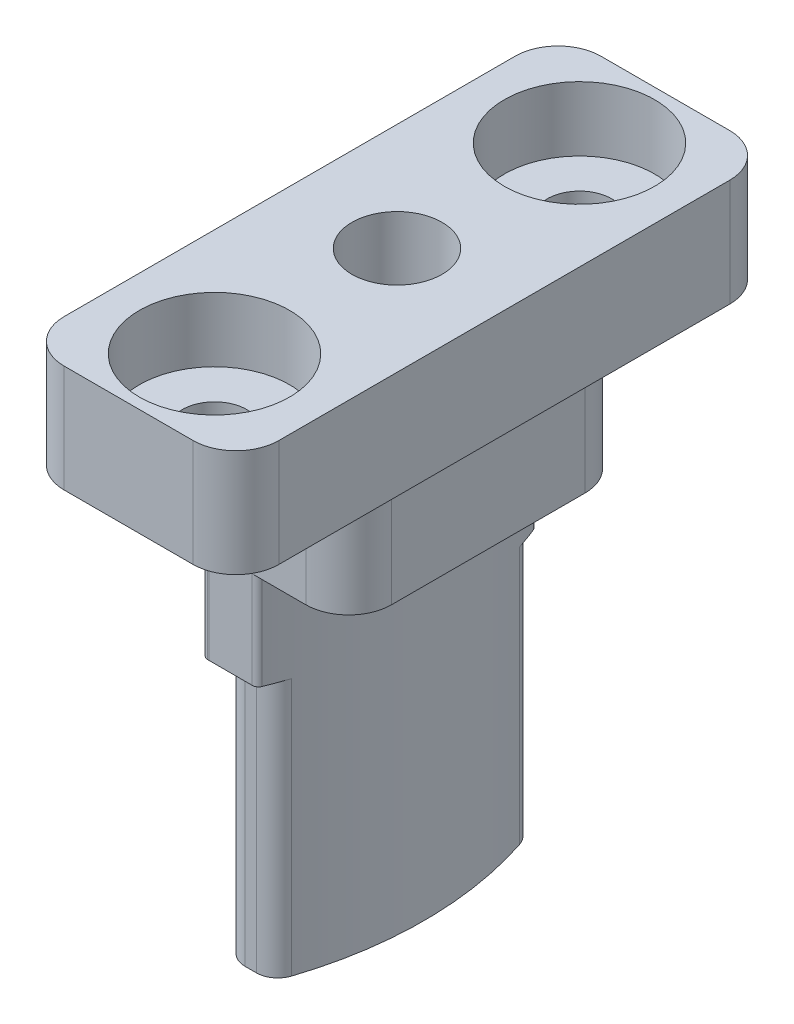
from build123d import *

# Parameters (mm, degrees)
SKETCH1_W           = 123.5
SKETCH1_H           = 81.5
BOSS_EXTRUDE1_DEPTH = 8
CHAMFER1_SIZE       = 10
SKETCH2_W           = 130
SKETCH2_H           = 88
BOSS_EXTRUDE2_DEPTH = 9
FILLET1_R           = 2
SKETCH3_W           = 124
SKETCH3_H           = 82
CUT_EXTRUDE1_DEPTH  = 2
FILLET2_R           = 2
SKETCH4_R           = 10
CUT_EXTRUDE2_DEPTH  = 18
SKETCH5_R           = 17
SKETCH5_R_2         = 14.5
BOSS_EXTRUDE3_DEPTH = 16.5
SKETCH6_W           = 170
SKETCH6_H           = 36.5
SKETCH6_W_2         = 114
SKETCH6_H_2         = 12
CUT_EXTRUDE3_DEPTH  = 12
FILLET3_R           = 1
SKETCH7_R           = 0.85
CUT_EXTRUDE4_DEPTH  = 20.75
SKETCH11_W          = 130
SKETCH11_H          = 10
CUT_EXTRUDE8_DEPTH  = 85.75
SKETCH13_R          = 2.1
CUT_EXTRUDE9_DEPTH  = 6
SKETCH15_R          = 2.1
SKETCH15_R_2        = 10
BOSS_EXTRUDE4_DEPTH = 3
SKETCH16_W          = 188.077165187
SKETCH16_H          = 117.101438596
SKETCH16_W_2        = 10
SKETCH16_H_2        = 25
CUT_EXTRUDE10_DEPTH = 27.5
CUT_EXTRUDE11_START = -5
SKETCH17_W          = 10
SKETCH17_H          = 25
SKETCH17_W_2        = 8.5
SKETCH17_H_2        = 13
CUT_EXTRUDE11_DEPTH = 22.5
FILLET4_R           = 2
SKETCH18_R          = 1.5
CUT_EXTRUDE12_DEPTH = 27.5
SKETCH19_R          = 3.5
CUT_EXTRUDE13_DEPTH = 3
FILLET5_R           = 0.3


with BuildPart() as part:
    # Sketch1 → Boss-Extrude1 (new body)
    with BuildSketch(Plane(origin=(0, 0, 0), x_dir=(1, 0, 0), z_dir=(0, 1, 0))):
        with Locations((61.75, -40.75)):
            Rectangle(SKETCH1_W, SKETCH1_H)
    extrude(amount=BOSS_EXTRUDE1_DEPTH)

    # Chamfer1
    chamfer1_edges = [part.edges().sort_by_distance(p)[0] for p in [
        (123.5, 4, 0),
        (123.5, 4, 81.5),
    ]]
    chamfer(chamfer1_edges, length=CHAMFER1_SIZE)

    # Sketch2 → Boss-Extrude2 (add)
    with BuildSketch(Plane.XZ):
        with Locations((61.75, 40.75)):
            Rectangle(SKETCH2_W, SKETCH2_H)
    extrude(amount=BOSS_EXTRUDE2_DEPTH)

    # Fillet1
    fillet1_edges = [part.edges().sort_by_distance(p)[0] for p in [
        (113.5, 4, 0),
        (123.5, 4, 71.5),
        (123.5, 4, 10),
        (113.5, 4, 81.5),
        (-3.25, -4.5, 84.75),
        (-3.25, -4.5, -3.25),
        (126.75, -4.5, -3.25),
        (126.75, -4.5, 84.75),
        (0, 4, 0),
        (0, 4, 81.5),
    ]]
    fillet(fillet1_edges, radius=FILLET1_R)

    # Sketch3 → Cut-Extrude1 (cut)
    with BuildSketch(Plane.XZ.offset(9)):
        with Locations((61.75, 40.75)):
            Rectangle(SKETCH3_W, SKETCH3_H)
    extrude(amount=-CUT_EXTRUDE1_DEPTH, mode=Mode.SUBTRACT)

    # Fillet2
    fillet2_edges = [part.edges().sort_by_distance(p)[0] for p in [
        (-0.25, -8, -0.25),
        (-0.25, -8, 81.75),
        (123.75, -8, 81.75),
        (123.75, -8, -0.25),
    ]]
    fillet(fillet2_edges, radius=FILLET2_R)

    # Sketch4 → Cut-Extrude2 (cut, through all)
    with BuildSketch(Plane(origin=(0, 8, 0), x_dir=(1, 0, 0), z_dir=(0, 1, 0))):
        with Locations((22.5, -20.85)):
            Circle(SKETCH4_R)
        with Locations((61.5, -20.85)):
            Circle(SKETCH4_R)
        with Locations((100.5, -20.85)):
            Circle(SKETCH4_R)
        with Locations((100.5, -60.65)):
            Circle(SKETCH4_R)
        with Locations((61.5, -60.65)):
            Circle(SKETCH4_R)
        with Locations((22.5, -60.65)):
            Circle(SKETCH4_R)
    extrude(amount=-CUT_EXTRUDE2_DEPTH, mode=Mode.SUBTRACT)

    # Sketch5 → Boss-Extrude3 (add)
    with BuildSketch(Plane.XZ.offset(7)):
        with Locations((22.5, 60.65)):
            Circle(SKETCH5_R)
        with Locations((22.5, 60.65)):
            Circle(SKETCH5_R_2, mode=Mode.SUBTRACT)
        with Locations((61.5, 60.65)):
            Circle(SKETCH5_R)
        with Locations((61.5, 60.65)):
            Circle(SKETCH5_R_2, mode=Mode.SUBTRACT)
        with Locations((100.5, 60.65)):
            Circle(SKETCH5_R)
        with Locations((100.5, 60.65)):
            Circle(SKETCH5_R_2, mode=Mode.SUBTRACT)
        with Locations((100.5, 20.85)):
            Circle(SKETCH5_R)
        with Locations((100.5, 20.85)):
            Circle(SKETCH5_R_2, mode=Mode.SUBTRACT)
        with Locations((61.5, 20.85)):
            Circle(SKETCH5_R)
        with Locations((61.5, 20.85)):
            Circle(SKETCH5_R_2, mode=Mode.SUBTRACT)
        with Locations((22.5, 20.85)):
            Circle(SKETCH5_R)
        with Locations((22.5, 20.85)):
            Circle(SKETCH5_R_2, mode=Mode.SUBTRACT)
    extrude(amount=BOSS_EXTRUDE3_DEPTH)

    # Sketch6 → Cut-Extrude3 (cut)
    with BuildSketch(Plane.XZ.offset(23.5)):
        with Locations((61.5, 20.85)):
            Rectangle(SKETCH6_W, SKETCH6_H)
        with Locations((61.5, 20.85)):
            Rectangle(SKETCH6_W_2, SKETCH6_H_2, mode=Mode.SUBTRACT)
        with Locations((61.5, 60.65)):
            Rectangle(SKETCH6_W, SKETCH6_H)
        with Locations((61.5, 60.65)):
            Rectangle(SKETCH6_W_2, SKETCH6_H_2, mode=Mode.SUBTRACT)
    extrude(amount=-CUT_EXTRUDE3_DEPTH, mode=Mode.SUBTRACT)

    # Fillet3
    fillet3_edges = [part.edges().sort_by_distance(p)[0] for p in [
        (87.299621218, -17.5, 66.65),
        (113.700378782, -17.5, 66.65),
        (113.700378782, -17.5, 54.65),
        (87.299621218, -17.5, 54.65),
        (9.299621218, -17.5, 54.65),
        (35.700378782, -17.5, 54.65),
        (6.594026279, -17.5, 54.65),
        (48.299621218, -17.5, 54.65),
        (74.700378782, -17.5, 54.65),
        (38.405973721, -17.5, 54.65),
        (45.594026279, -17.5, 54.65),
        (77.405973721, -17.5, 54.65),
        (84.594026279, -17.5, 54.65),
        (35.700378782, -17.5, 66.65),
        (9.299621218, -17.5, 66.65),
        (38.405973721, -17.5, 66.65),
        (45.594026279, -17.5, 66.65),
        (74.700378782, -17.5, 66.65),
        (48.299621218, -17.5, 66.65),
        (77.405973721, -17.5, 66.65),
        (84.594026279, -17.5, 66.65),
        (116.405973721, -17.5, 66.65),
        (116.405973721, -17.5, 54.65),
        (6.594026279, -17.5, 66.65),
        (35.700378782, -17.5, 14.85),
        (9.299621218, -17.5, 14.85),
        (9.299621218, -17.5, 26.85),
        (35.700378782, -17.5, 26.85),
        (113.700378782, -17.5, 26.85),
        (87.299621218, -17.5, 26.85),
        (116.405973721, -17.5, 26.85),
        (74.700378782, -17.5, 26.85),
        (48.299621218, -17.5, 26.85),
        (84.594026279, -17.5, 26.85),
        (77.405973721, -17.5, 26.85),
        (45.594026279, -17.5, 26.85),
        (38.405973721, -17.5, 26.85),
        (87.299621218, -17.5, 14.85),
        (113.700378782, -17.5, 14.85),
        (84.594026279, -17.5, 14.85),
        (77.405973721, -17.5, 14.85),
        (48.299621218, -17.5, 14.85),
        (74.700378782, -17.5, 14.85),
        (45.594026279, -17.5, 14.85),
        (38.405973721, -17.5, 14.85),
        (6.594026279, -17.5, 14.85),
        (6.594026279, -17.5, 26.85),
        (116.405973721, -17.5, 14.85),
    ]]
    fillet(fillet3_edges, radius=FILLET3_R)

    # Sketch7 → Cut-Extrude4 (cut)
    with BuildSketch(Plane.XZ.offset(23.5)):
        with Locations((6.75, 20.85)):
            Circle(SKETCH7_R)
        with Locations((38.25, 20.85)):
            Circle(SKETCH7_R)
        with Locations((45.75, 20.85)):
            Circle(SKETCH7_R)
        with Locations((77.25, 20.85)):
            Circle(SKETCH7_R)
        with Locations((84.75, 20.85)):
            Circle(SKETCH7_R)
        with Locations((116.25, 20.85)):
            Circle(SKETCH7_R)
        with Locations((116.25, 60.65)):
            Circle(SKETCH7_R)
        with Locations((84.75, 60.65)):
            Circle(SKETCH7_R)
        with Locations((77.25, 60.65)):
            Circle(SKETCH7_R)
        with Locations((45.75, 60.65)):
            Circle(SKETCH7_R)
        with Locations((38.25, 60.65)):
            Circle(SKETCH7_R)
        with Locations((6.75, 60.65)):
            Circle(SKETCH7_R)
    extrude(amount=-CUT_EXTRUDE4_DEPTH, mode=Mode.SUBTRACT)

    # Sketch11 → Cut-Extrude8 (cut, through all)
    with BuildSketch(Plane(origin=(0, 0, 0), x_dir=(-1, 0, 0), z_dir=(0, 0, -1))):
        with Locations((-61.75, 5)):
            Rectangle(SKETCH11_W, SKETCH11_H)
    extrude(amount=-CUT_EXTRUDE8_DEPTH, mode=Mode.SUBTRACT)

    # Sketch13 → Cut-Extrude9 (cut)
    with BuildSketch(Plane(origin=(0, 0, 0), x_dir=(1, 0, 0), z_dir=(0, 1, 0))):
        with Locations((116.25, -60.65)):
            Circle(SKETCH13_R)
        with Locations((85.5, -60.65)):
            Circle(SKETCH13_R)
        with Locations((76.5, -60.65)):
            Circle(SKETCH13_R)
        with Locations((116.25, -20.85)):
            Circle(SKETCH13_R)
        with Locations((85.5, -20.85)):
            Circle(SKETCH13_R)
        with Locations((76.5, -20.85)):
            Circle(SKETCH13_R)
        with Locations((46.5, -20.85)):
            Circle(SKETCH13_R)
        with Locations((37.5, -20.85)):
            Circle(SKETCH13_R)
        with Locations((6.75, -20.85)):
            Circle(SKETCH13_R)
        with Locations((6.75, -60.65)):
            Circle(SKETCH13_R)
        with Locations((37.5, -60.65)):
            Circle(SKETCH13_R)
        with Locations((46.5, -60.65)):
            Circle(SKETCH13_R)
    extrude(amount=-CUT_EXTRUDE9_DEPTH, mode=Mode.SUBTRACT)

    # Sketch15 → Boss-Extrude4 (add)
    with BuildSketch(Plane(origin=(0, 0, 0), x_dir=(1, 0, 0), z_dir=(0, 1, 0))):
        with BuildLine():
            Line((126.75, -82.75), (126.75, 1.25))
            ThreePointArc((126.75, 1.25), (126.164213562, 2.664213562), (124.75, 3.25))
            Line((124.75, 3.25), (-1.25, 3.25))
            ThreePointArc((-1.25, 3.25), (-2.664213562, 2.664213562), (-3.25, 1.25))
            Line((-3.25, 1.25), (-3.25, -82.75))
            ThreePointArc((-3.25, -82.75), (-2.664213562, -84.164213562), (-1.25, -84.75))
            Line((-1.25, -84.75), (124.75, -84.75))
            ThreePointArc((124.75, -84.75), (126.164213562, -84.164213562), (126.75, -82.75))
        make_face()
        with Locations((6.75, -60.65)):
            Circle(SKETCH15_R, mode=Mode.SUBTRACT)
        with Locations((22.5, -60.65)):
            Circle(SKETCH15_R_2, mode=Mode.SUBTRACT)
        with Locations((37.5, -60.65)):
            Circle(SKETCH15_R, mode=Mode.SUBTRACT)
        with Locations((46.5, -60.65)):
            Circle(SKETCH15_R, mode=Mode.SUBTRACT)
        with Locations((61.5, -60.65)):
            Circle(SKETCH15_R_2, mode=Mode.SUBTRACT)
        with Locations((76.5, -60.65)):
            Circle(SKETCH15_R, mode=Mode.SUBTRACT)
        with Locations((100.5, -60.65)):
            Circle(SKETCH15_R_2, mode=Mode.SUBTRACT)
        with Locations((116.25, -60.65)):
            Circle(SKETCH15_R, mode=Mode.SUBTRACT)
        with Locations((116.25, -20.85)):
            Circle(SKETCH15_R, mode=Mode.SUBTRACT)
        with Locations((100.5, -20.85)):
            Circle(SKETCH15_R_2, mode=Mode.SUBTRACT)
        with Locations((85.5, -20.85)):
            Circle(SKETCH15_R, mode=Mode.SUBTRACT)
        with Locations((76.5, -20.85)):
            Circle(SKETCH15_R, mode=Mode.SUBTRACT)
        with Locations((61.5, -20.85)):
            Circle(SKETCH15_R_2, mode=Mode.SUBTRACT)
        with Locations((46.5, -20.85)):
            Circle(SKETCH15_R, mode=Mode.SUBTRACT)
        with Locations((37.5, -20.85)):
            Circle(SKETCH15_R, mode=Mode.SUBTRACT)
        with Locations((22.5, -20.85)):
            Circle(SKETCH15_R_2, mode=Mode.SUBTRACT)
        with Locations((85.5, -60.65)):
            Circle(SKETCH15_R, mode=Mode.SUBTRACT)
        with Locations((6.75, -20.85)):
            Circle(SKETCH15_R, mode=Mode.SUBTRACT)
    extrude(amount=BOSS_EXTRUDE4_DEPTH)

    # Sketch16 → Cut-Extrude10 (cut, through all)
    with BuildSketch(Plane(origin=(0, 3, 0), x_dir=(1, 0, 0), z_dir=(0, 1, 0))):
        with Locations((70.835120056, -43.47328927)):
            Rectangle(SKETCH16_W, SKETCH16_H)
        with Locations((116.25, -60.65)):
            Rectangle(SKETCH16_W_2, SKETCH16_H_2, mode=Mode.SUBTRACT)
    extrude(amount=-CUT_EXTRUDE10_DEPTH, mode=Mode.SUBTRACT)

    # Sketch17 → Cut-Extrude11 (cut, through all)
    with BuildSketch(Plane(origin=(0, 3, 0), x_dir=(1, 0, 0), z_dir=(0, 1, 0)).offset(CUT_EXTRUDE11_START)):
        with Locations((116.25, -60.65)):
            Rectangle(SKETCH17_W, SKETCH17_H)
        with Locations((116.25, -60.65)):
            Rectangle(SKETCH17_W_2, SKETCH17_H_2, mode=Mode.SUBTRACT)
    extrude(amount=-CUT_EXTRUDE11_DEPTH, mode=Mode.SUBTRACT)

    # Fillet4
    fillet4_edges = [part.edges().sort_by_distance(p)[0] for p in [
        (120.5, -4.5, 54.15),
        (121.25, 0.5, 48.15),
        (120.5, -4.5, 67.15),
        (112, -4.5, 54.15),
        (112, -4.5, 67.15),
        (121.25, 0.5, 73.15),
        (111.25, 0.5, 73.15),
        (111.25, 0.5, 48.15),
    ]]
    fillet(fillet4_edges, radius=FILLET4_R)

    # Sketch18 → Cut-Extrude12 (cut, through all)
    with BuildSketch(Plane(origin=(0, 3, 0), x_dir=(1, 0, 0), z_dir=(0, 1, 0))):
        with Locations((116.25, -52.15)):
            Circle(SKETCH18_R)
        with Locations((116.25, -69.15)):
            Circle(SKETCH18_R)
    extrude(amount=-CUT_EXTRUDE12_DEPTH, mode=Mode.SUBTRACT)

    # Sketch19 → Cut-Extrude13 (cut)
    with BuildSketch(Plane(origin=(0, 3, 0), x_dir=(1, 0, 0), z_dir=(0, 1, 0))):
        with Locations((116.25, -52.15)):
            Circle(SKETCH19_R)
        with Locations((116.25, -69.15)):
            Circle(SKETCH19_R)
    extrude(amount=-CUT_EXTRUDE13_DEPTH, mode=Mode.SUBTRACT)

    # Fillet5
    fillet5_edges = [part.edges().sort_by_distance(p)[0] for p in [
        (116.208278072, -9.25, 67.15),
        (116.208278072, -9.25, 54.15),
        (113.493918477, -9.25, 67.084911236),
        (113.493918477, -9.25, 54.215088764),
    ]]
    fillet(fillet5_edges, radius=FILLET5_R)


solid = part.part
